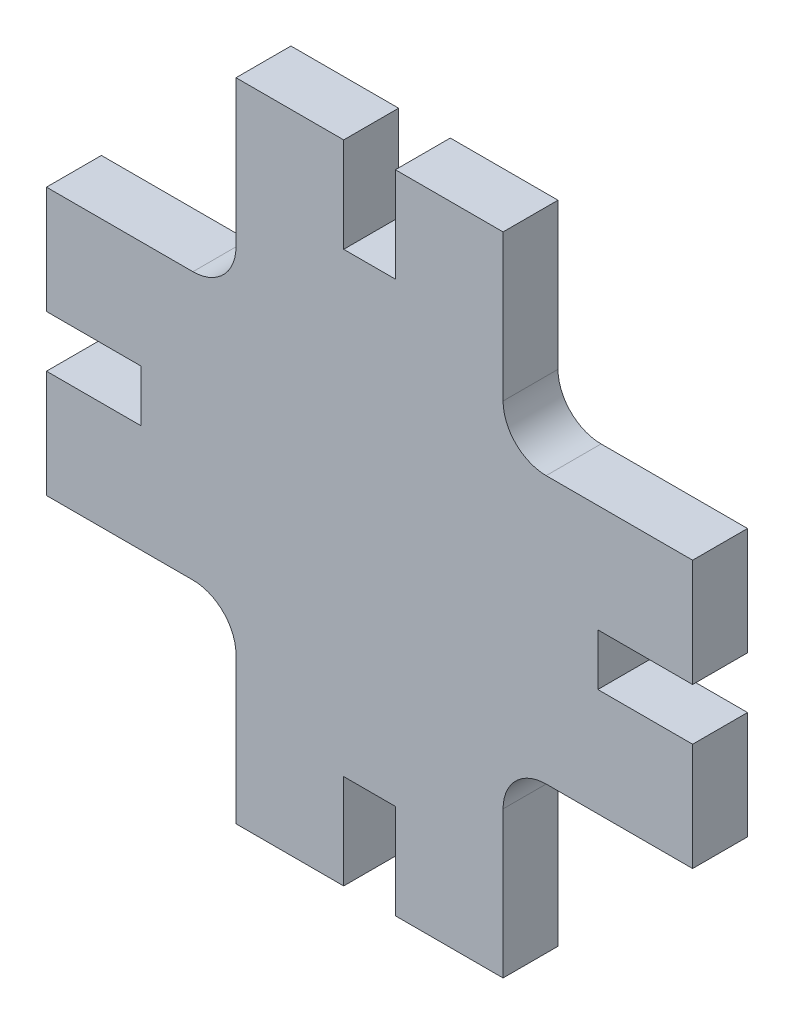
from build123d import *

# Parameters (mm, degrees)
SALIENTE_EXTRUIR1_DEPTH = 5.1


with BuildPart() as part:
    # Croquis1 → Saliente-Extruir1 (new body)
    with BuildSketch(Plane.XY):
        with BuildLine():
            Line((0, 0), (10, 0))
            Line((10, 0), (10, 8.8))
            Line((10, 8.8), (14.8, 8.8))
            Line((14.8, 8.8), (14.8, 0))
            Line((14.8, 0), (24.8, 0))
            Line((24.8, 0), (24.8, 13.6))
            ThreePointArc((24.8, 13.6), (25.971572875, 16.428427125), (28.8, 17.6))
            Line((28.8, 17.6), (42.4, 17.6))
            Line((42.4, 17.6), (42.4, 27.6))
            Line((42.4, 27.6), (33.6, 27.6))
            Line((33.6, 27.6), (33.6, 32.4))
            Line((33.6, 32.4), (42.4, 32.4))
            Line((42.4, 32.4), (42.4, 42.4))
            Line((42.4, 42.4), (28.8, 42.4))
            ThreePointArc((28.8, 42.4), (25.971572875, 43.571572875), (24.8, 46.4))
            Line((24.8, 46.4), (24.8, 60))
            Line((24.8, 60), (14.8, 60))
            Line((14.8, 60), (14.8, 51.2))
            Line((14.8, 51.2), (10, 51.2))
            Line((10, 51.2), (10, 60))
            Line((10, 60), (0, 60))
            Line((0, 60), (0, 46.4))
            ThreePointArc((0, 46.4), (-1.171572875, 43.571572875), (-4, 42.4))
            Line((-4, 42.4), (-17.6, 42.4))
            Line((-17.6, 42.4), (-17.6, 32.4))
            Line((-17.6, 32.4), (-8.8, 32.4))
            Line((-8.8, 32.4), (-8.8, 27.6))
            Line((-8.8, 27.6), (-17.6, 27.6))
            Line((-17.6, 27.6), (-17.6, 17.6))
            Line((-17.6, 17.6), (-4, 17.6))
            ThreePointArc((-4, 17.6), (-1.171572875, 16.428427125), (0, 13.6))
            Line((0, 13.6), (0, 0))
        make_face()
    extrude(amount=SALIENTE_EXTRUIR1_DEPTH)


solid = part.part
